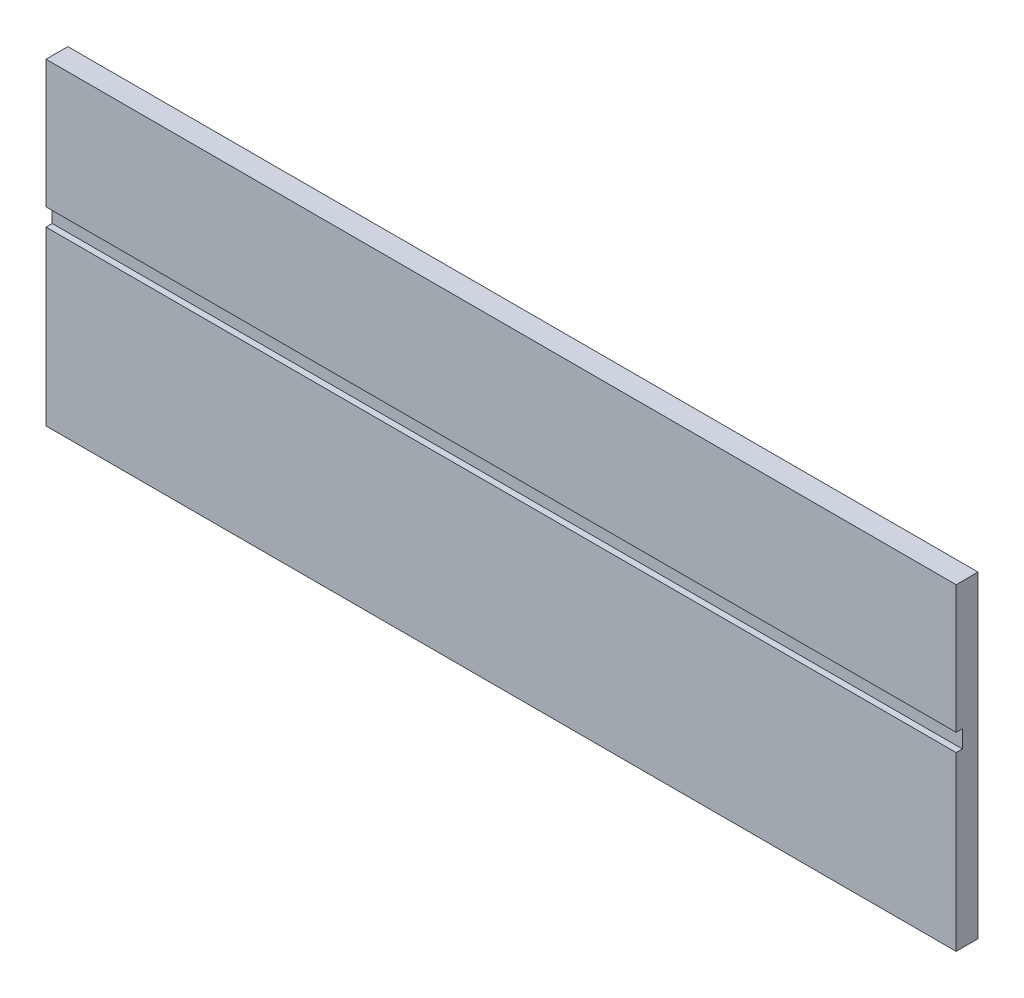
from build123d import *

# Parameters (mm, degrees)
HEADTOPOUTLINE_W                = 740.41
HEADTOPOUTLINE_H                = 258.3688
HEADTOPOUTLINE_THICKNESS_DEPTH  = 17.78
HEADTOP_DISPLAYSLOT_W           = 740.41
HEADTOP_DISPLAYSLOT_H           = 14.3002
HEADTOP_DISPLAYSLOT_DEPTH_DEPTH = 5.08


with BuildPart() as part:
    # HeadTopOutline → HeadTopOutline_Thickness (new body)
    with BuildSketch(Plane.XY):
        with Locations((-233.045, -5665.1906)):
            Rectangle(HEADTOPOUTLINE_W, HEADTOPOUTLINE_H)
    extrude(amount=-HEADTOPOUTLINE_THICKNESS_DEPTH)

    # HeadTop_DisplaySlot → HeadTop_DisplaySlot_Depth (cut)
    with BuildSketch(Plane.XY):
        with Locations((-233.045, -5647.1439)):
            Rectangle(HEADTOP_DISPLAYSLOT_W, HEADTOP_DISPLAYSLOT_H)
    extrude(amount=-HEADTOP_DISPLAYSLOT_DEPTH_DEPTH, mode=Mode.SUBTRACT)


solid = part.part
